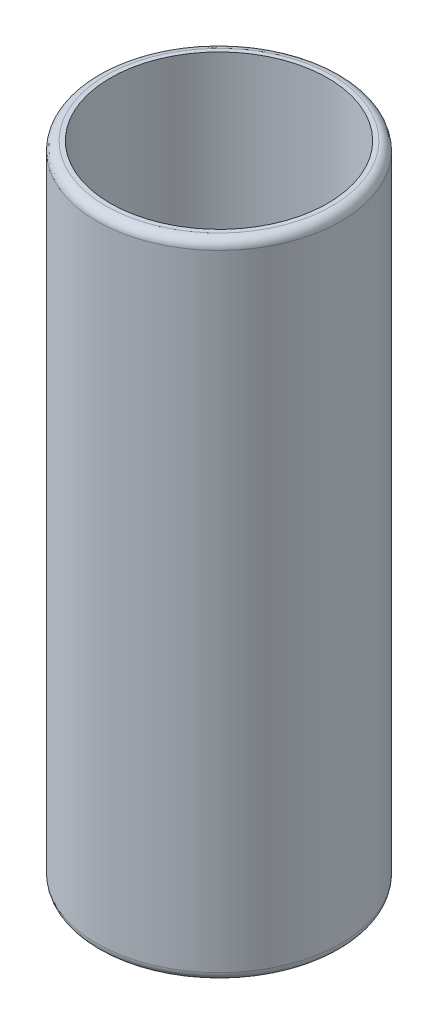
from build123d import *

# Parameters (mm, degrees)
SKETCH1_R           = 13.75
BOSS_EXTRUDE1_DEPTH = 72.5
SKETCH2_R           = 12.25
CUT_EXTRUDE1_DEPTH  = 71
FILLET1_R           = 1


with BuildPart() as part:
    # Sketch1 → Boss-Extrude1 (new body)
    with BuildSketch(Plane(origin=(0, 0, 0), x_dir=(1, 0, 0), z_dir=(0, 1, 0))):
        Circle(SKETCH1_R)
    extrude(amount=BOSS_EXTRUDE1_DEPTH)

    # Sketch2 → Cut-Extrude1 (cut)
    with BuildSketch(Plane(origin=(0, 72.5, 0), x_dir=(1, 0, 0), z_dir=(0, 1, 0))):
        Circle(SKETCH2_R)
    extrude(amount=-CUT_EXTRUDE1_DEPTH, mode=Mode.SUBTRACT)

    # Fillet1
    fillet1_edges = [part.edges().sort_by_distance(p)[0] for p in [
        (-13.75, 0, 0),
        (-13.75, 72.5, 0),
    ]]
    fillet(fillet1_edges, radius=FILLET1_R)


solid = part.part
